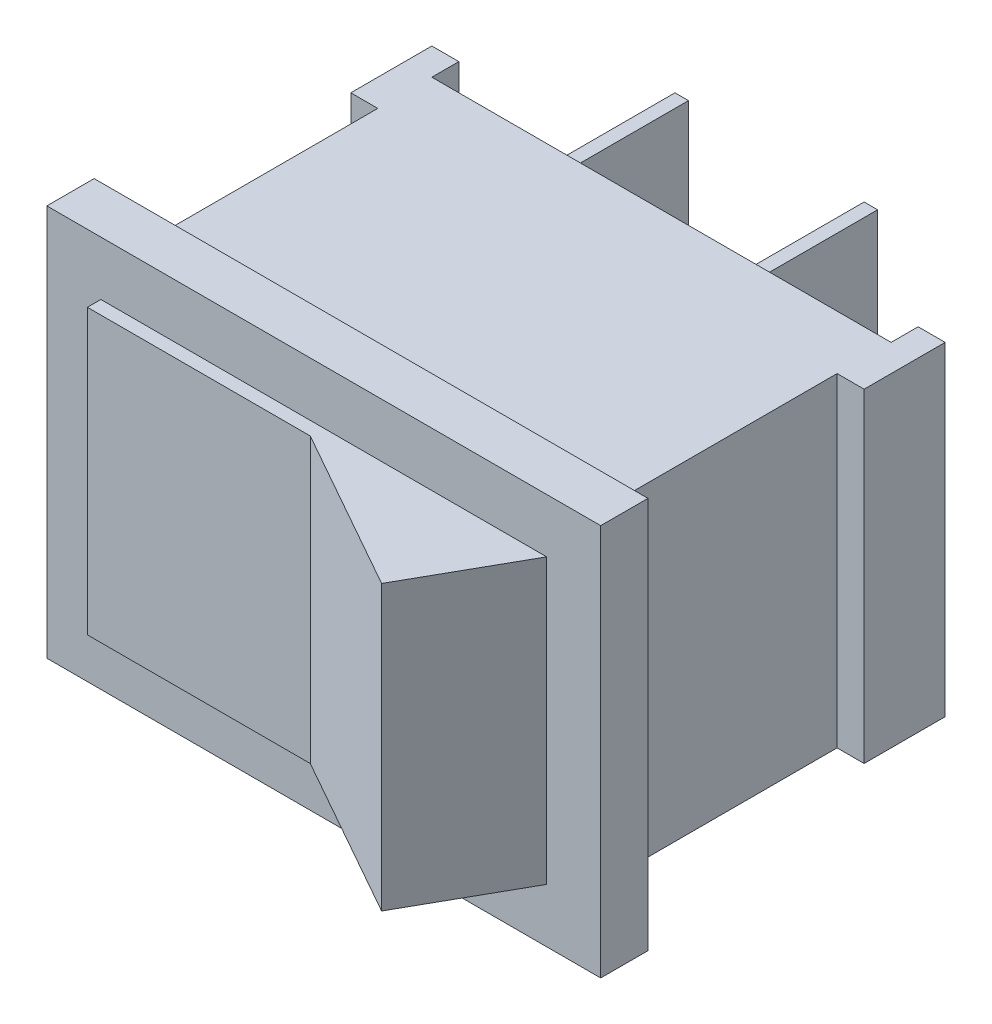
from build123d import *

# Parameters (mm, degrees)
SCHIZZO1_W                   = 20.5
SCHIZZO1_H                   = 14.5
ESTRUSIONE_ESTRUSIONE1_DEPTH = 1.75
SCHIZZO2_W                   = 17
SCHIZZO2_H                   = 12
ESTRUSIONE_ESTRUSIONE2_DEPTH = 10.75
SCHIZZO3_W                   = 3
SCHIZZO3_H                   = 12
ESTRUSIONE_ESTRUSIONE3_DEPTH = 1
SCHIZZO4_W                   = 3
SCHIZZO4_H                   = 12
ESTRUSIONE_ESTRUSIONE4_DEPTH = 1
SCHIZZO6_W                   = 8.25
SCHIZZO6_H                   = 10.5
ESTRUSIONE_ESTRUSIONE5_DEPTH = 0.5
ESTRUSIONE_ESTRUSIONE6_DEPTH = 10.5
SCHIZZO9_W                   = 0.5
SCHIZZO9_H                   = 4
ESTRUSIONE_ESTRUSIONE7_DEPTH = 8


with BuildPart() as part:
    # Schizzo1 → Estrusione-Estrusione1 (new body)
    with BuildSketch(Plane.XY):
        Rectangle(SCHIZZO1_W, SCHIZZO1_H)
    extrude(amount=ESTRUSIONE_ESTRUSIONE1_DEPTH)

    # Schizzo2 → Estrusione-Estrusione2 (add)
    with BuildSketch(Plane(origin=(0, 0, 0), x_dir=(-1, 0, 0), z_dir=(0, 0, -1))):
        Rectangle(SCHIZZO2_W, SCHIZZO2_H)
    extrude(amount=ESTRUSIONE_ESTRUSIONE2_DEPTH)

    # Schizzo3 → Estrusione-Estrusione3 (add)
    with BuildSketch(Plane(origin=(8.5, 0, 0), x_dir=(0, 0, -1), z_dir=(1, 0, 0))):
        with Locations((10.25, 0)):
            Rectangle(SCHIZZO3_W, SCHIZZO3_H)
    extrude(amount=ESTRUSIONE_ESTRUSIONE3_DEPTH)

    # Schizzo4 → Estrusione-Estrusione4 (add)
    with BuildSketch(Plane.ZY.offset(8.5)):
        with Locations((-10.25, 0)):
            Rectangle(SCHIZZO4_W, SCHIZZO4_H)
    extrude(amount=ESTRUSIONE_ESTRUSIONE4_DEPTH)

    # Schizzo6 → Estrusione-Estrusione5 (add)
    with BuildSketch(Plane.XY.offset(1.75)):
        with Locations((-4.125, 0)):
            Rectangle(SCHIZZO6_W, SCHIZZO6_H)
    extrude(amount=ESTRUSIONE_ESTRUSIONE5_DEPTH)

    # Schizzo8 → Estrusione-Estrusione6 (add)
    with BuildSketch(Plane(origin=(0, 5.25, 0), x_dir=(1, 0, 0), z_dir=(0, 1, 0))):
        Polygon((0, -2.25), (6.048387887, -5.65769108), (8.25, -1.75), (0, -1.75), align=None)
    extrude(amount=-ESTRUSIONE_ESTRUSIONE6_DEPTH)

    # Schizzo9 → Estrusione-Estrusione7 (add)
    with BuildSketch(Plane(origin=(0, 0, -10.75), x_dir=(-1, 0, 0), z_dir=(0, 0, -1))):
        with Locations((7.25, 0)):
            Rectangle(SCHIZZO9_W, SCHIZZO9_H)
        with Locations((0.25, 0)):
            Rectangle(SCHIZZO9_W, SCHIZZO9_H)
    extrude(amount=ESTRUSIONE_ESTRUSIONE7_DEPTH)


solid = part.part
